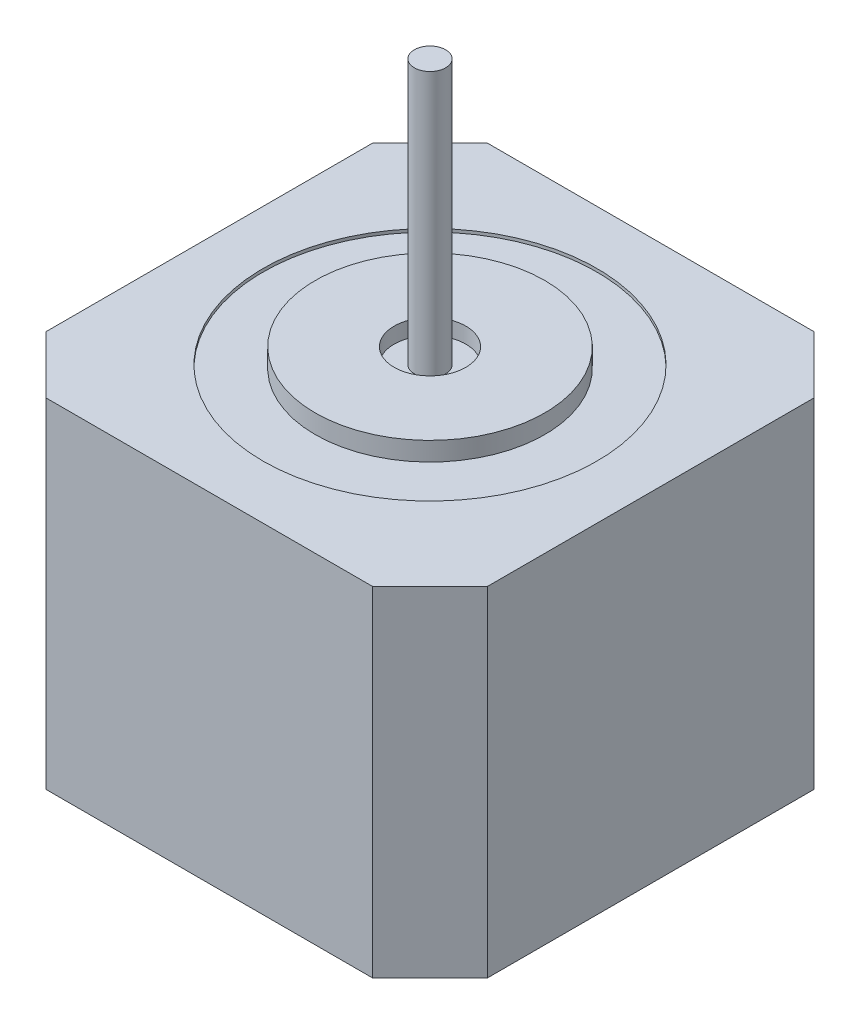
from build123d import *

# Parameters (mm, degrees)
SKETCH2_W           = 42.3
SKETCH2_H           = 42.3
BOSS_EXTRUDE1_DEPTH = 32.5
CHAMFER1_SIZE       = 5.5
SKETCH3_R           = 11
SKETCH3_R_2         = 3.430858596
BOSS_EXTRUDE2_DEPTH = 1.5
SKETCH4_R           = 16
SKETCH4_R_2         = 11
CUT_EXTRUDE1_DEPTH  = 0.3
SKETCH5_R           = 1.5
BOSS_EXTRUDE3_DEPTH = 25.4


with BuildPart() as part:
    # Sketch2 → Boss-Extrude1 (new body)
    with BuildSketch(Plane(origin=(0, 0, 0), x_dir=(1, 0, 0), z_dir=(0, 1, 0))):
        Rectangle(SKETCH2_W, SKETCH2_H)
    extrude(amount=BOSS_EXTRUDE1_DEPTH)

    # Chamfer1
    chamfer1_edges = [part.edges().sort_by_distance(p)[0] for p in [
        (21.15, 16.25, 21.15),
        (-21.15, 16.25, 21.15),
        (-21.15, 16.25, -21.15),
        (21.15, 16.25, -21.15),
    ]]
    chamfer(chamfer1_edges, length=CHAMFER1_SIZE)

    # Sketch3 → Boss-Extrude2 (add)
    with BuildSketch(Plane(origin=(0, 32.5, 0), x_dir=(1, 0, 0), z_dir=(0, 1, 0))):
        Circle(SKETCH3_R)
        Circle(SKETCH3_R_2, mode=Mode.SUBTRACT)
    extrude(amount=BOSS_EXTRUDE2_DEPTH)

    # Sketch4 → Cut-Extrude1 (cut)
    with BuildSketch(Plane(origin=(0, 32.5, 0), x_dir=(1, 0, 0), z_dir=(0, 1, 0))):
        Circle(SKETCH4_R)
        Circle(SKETCH4_R_2, mode=Mode.SUBTRACT)
    extrude(amount=-CUT_EXTRUDE1_DEPTH, mode=Mode.SUBTRACT)

    # Sketch5 → Boss-Extrude3 (add)
    with BuildSketch(Plane(origin=(0, 32.5, 0), x_dir=(1, 0, 0), z_dir=(0, 1, 0))):
        Circle(SKETCH5_R)
    extrude(amount=BOSS_EXTRUDE3_DEPTH)


solid = part.part
